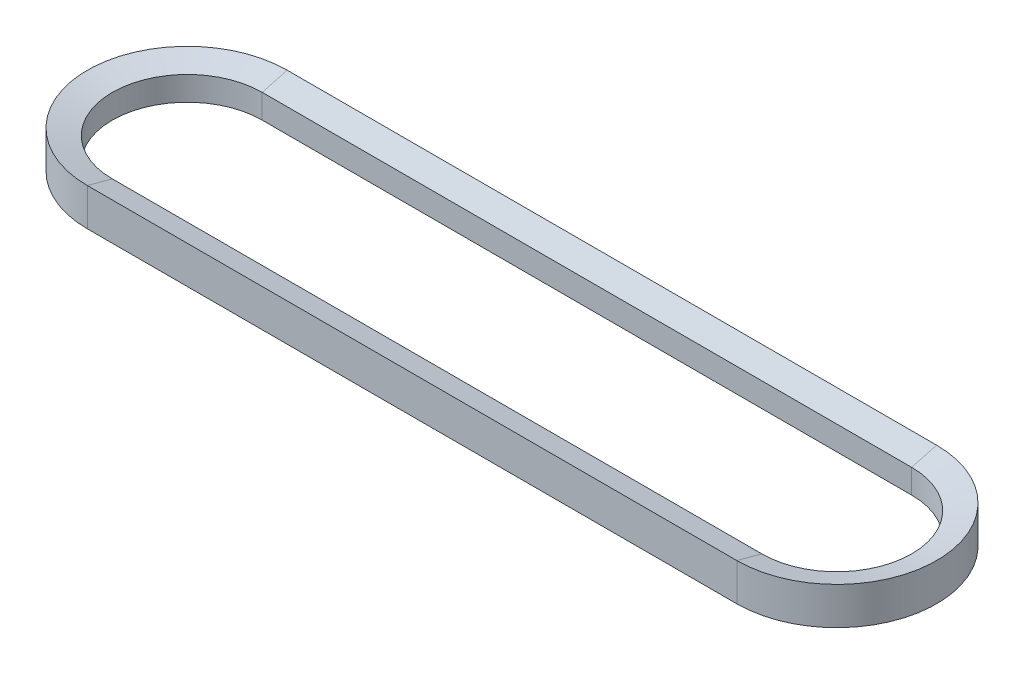
from build123d import *


with BuildPart() as part:
    # Sweep1: sweep along a path in Sketch1
    with BuildLine(Plane(origin=(0, 0, 0), x_dir=(1, 0, 0), z_dir=(0, 1, 0))) as sweep1_path:
        Line((165.1, -50.8), (-165.1, -50.8))
        ThreePointArc((-165.1, -50.8), (-215.9, 0), (-165.1, 50.8))
        Line((-165.1, 50.8), (165.1, 50.8))
        ThreePointArc((165.1, 50.8), (215.9, 0), (165.1, -50.8))
    # Sketch2 → Sweep1 (sweep)
    with BuildSketch(Plane(origin=(-165.1, 0, -50.8), x_dir=(0, 0, 1), z_dir=(-1, 0, 0))):
        Polygon((0, 0), (0, 9.525), (12.7, 6.122045256), (12.7, -6.122045256), (0, -9.525), align=None)
    sweep(path=sweep1_path.line)


solid = part.part
